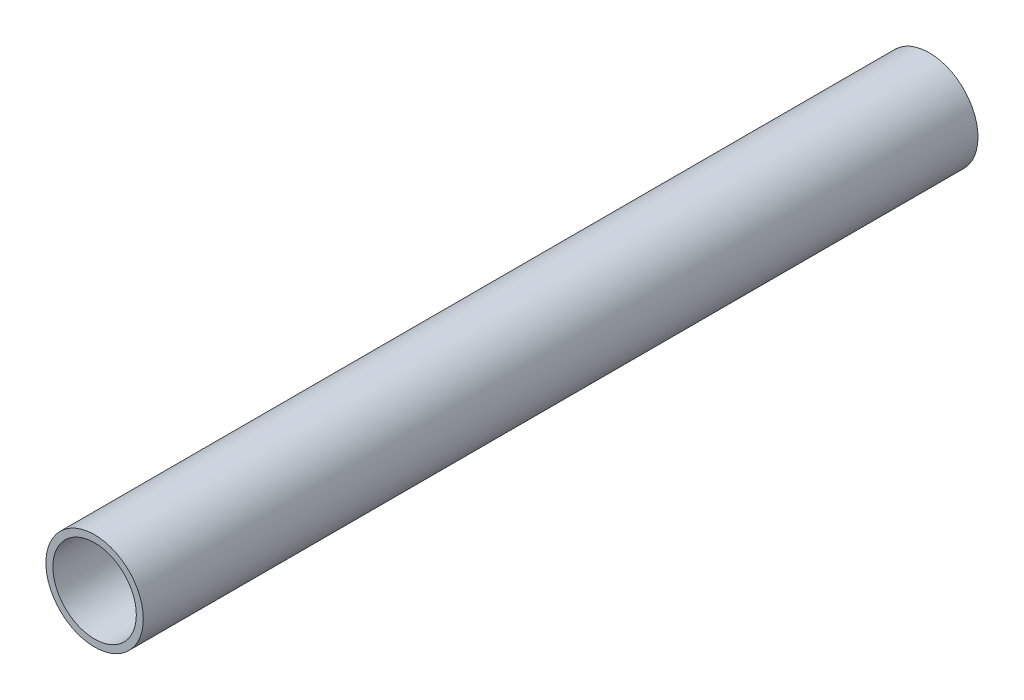
from build123d import *

# Parameters (mm, degrees)
SKETCH1_R           = 11.1125
SKETCH1_R_2         = 9.525
BOSS_EXTRUDE1_DEPTH = 95.25
SCALE1_SCALE        = 0.35


with BuildPart() as part:
    # Sketch1 → Boss-Extrude1 (new body, symmetric)
    with BuildSketch(Plane.XY):
        Circle(SKETCH1_R)
        Circle(SKETCH1_R_2, mode=Mode.SUBTRACT)
    extrude(amount=BOSS_EXTRUDE1_DEPTH, both=True)


with BuildPart() as part_1:
    # Scale1: scaled about (0, 0, 0)
    add(part.part.scale(SCALE1_SCALE))


solid = part_1.part
